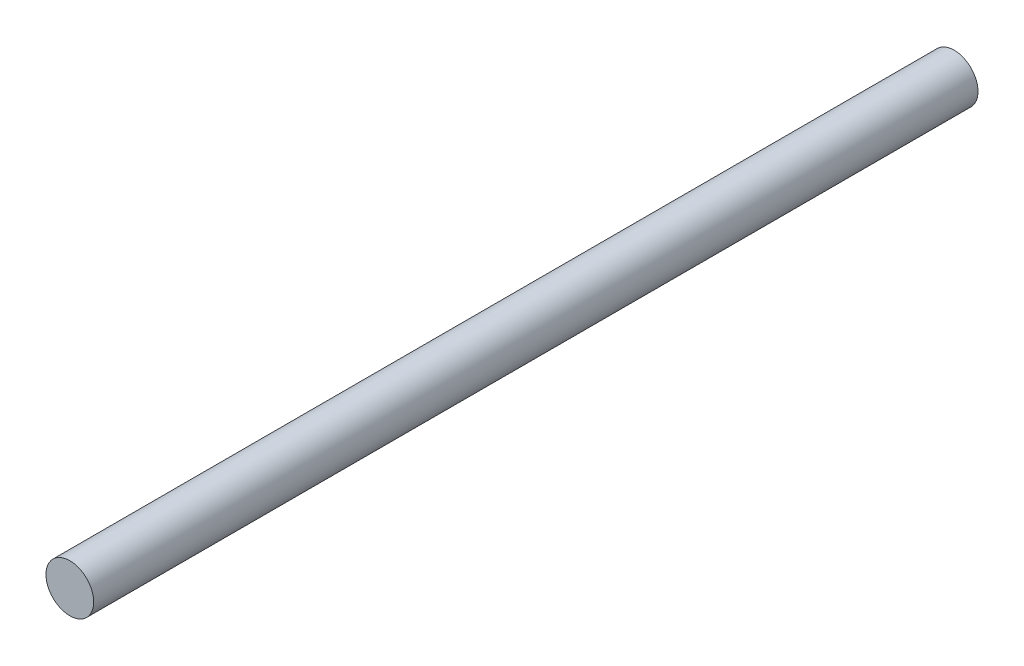
from build123d import *

# Parameters (mm, degrees)
SKETCH1_R           = 9.4488
BOSS_EXTRUDE1_DEPTH = 350


with BuildPart() as part:
    # Sketch1 → Boss-Extrude1 (new body)
    with BuildSketch(Plane.XY):
        Circle(SKETCH1_R)
    extrude(amount=BOSS_EXTRUDE1_DEPTH)


solid = part.part
